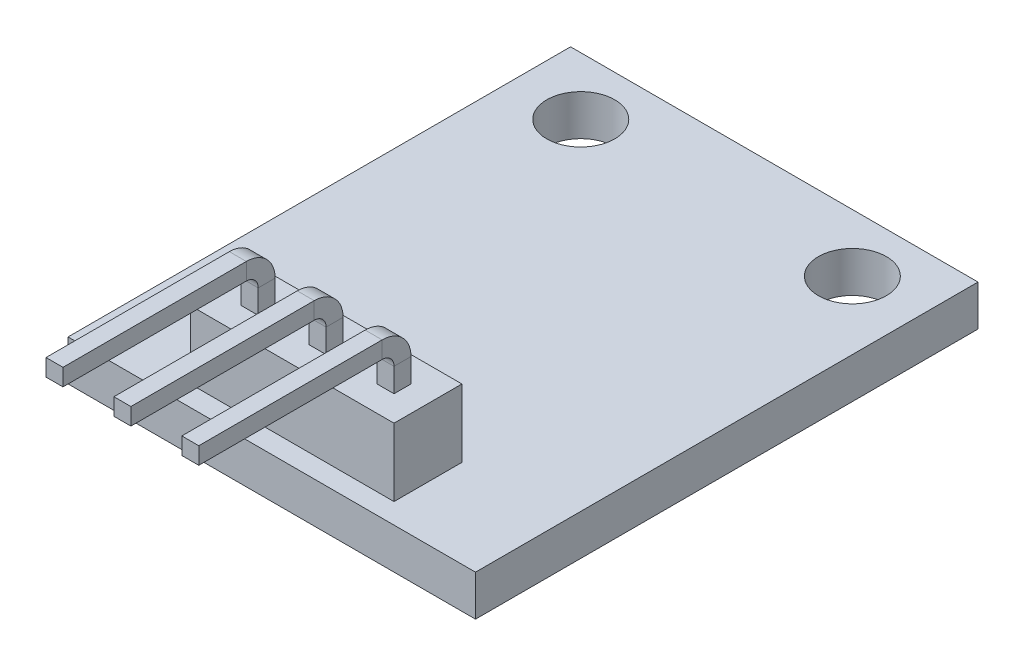
from build123d import *

# Parameters (mm, degrees)
SKETCH1_W           = 15.24
SKETCH1_H           = 18.796
SKETCH1_R           = 1.27
BOSS_EXTRUDE1_DEPTH = 1.524
SKETCH2_W           = 7.62
SKETCH2_H           = 2.54
BOSS_EXTRUDE2_DEPTH = 2.54
SKETCH4_W           = 0.635
SKETCH4_H           = 0.635
LPATTERN1_COUNT     = 2
LPATTERN1_PITCH     = 2.54
LPATTERN1_COL_COUNT = 2
LPATTERN1_COL_PITCH = 2.54


with BuildPart() as part:
    # Sketch1 → Boss-Extrude1 (new body)
    with BuildSketch(Plane(origin=(0, 0, 0), x_dir=(1, 0, 0), z_dir=(0, 1, 0))):
        Rectangle(SKETCH1_W, SKETCH1_H)
        with Locations((-5.08, 7.239)):
            Circle(SKETCH1_R, mode=Mode.SUBTRACT)
        with Locations((5.08, 7.239)):
            Circle(SKETCH1_R, mode=Mode.SUBTRACT)
    extrude(amount=BOSS_EXTRUDE1_DEPTH)

    # Sketch2 → Boss-Extrude2 (add)
    with BuildSketch(Plane(origin=(0, 1.524, 0), x_dir=(1, 0, 0), z_dir=(0, 1, 0))):
        with Locations((0, -7.366)):
            Rectangle(SKETCH2_W, SKETCH2_H)
    extrude(amount=BOSS_EXTRUDE2_DEPTH)

    # Sweep1: sweep along a path in Sketch3
    with BuildLine(Plane(origin=(0, 0, 0), x_dir=(0, 0, -1), z_dir=(1, 0, 0))) as sweep1_path:
        Line((-7.366, 4.064), (-7.366, 4.953))
        ThreePointArc((-7.366, 4.953), (-7.589184633, 5.491815367), (-8.128, 5.715))
        Line((-8.128, 5.715), (-14.986, 5.715))
    # Sketch4 → Sweep1 (sweep)
    with BuildSketch(Plane.XY.offset(14.986)):
        with Locations((0, 5.715)):
            Rectangle(SKETCH4_W, SKETCH4_H)
    sweep1 = sweep(path=sweep1_path.line)

    # LPattern1: Sweep1 ×2
    with Locations(*[(i * LPATTERN1_PITCH, 0, 0) for i in range(1, LPATTERN1_COUNT)]):
        add(sweep1)

    # LPattern1 col: Sweep1 ×2
    with Locations(*[(-i * LPATTERN1_COL_PITCH, 0, 0) for i in range(1, LPATTERN1_COL_COUNT)]):
        add(sweep1)


solid = part.part
